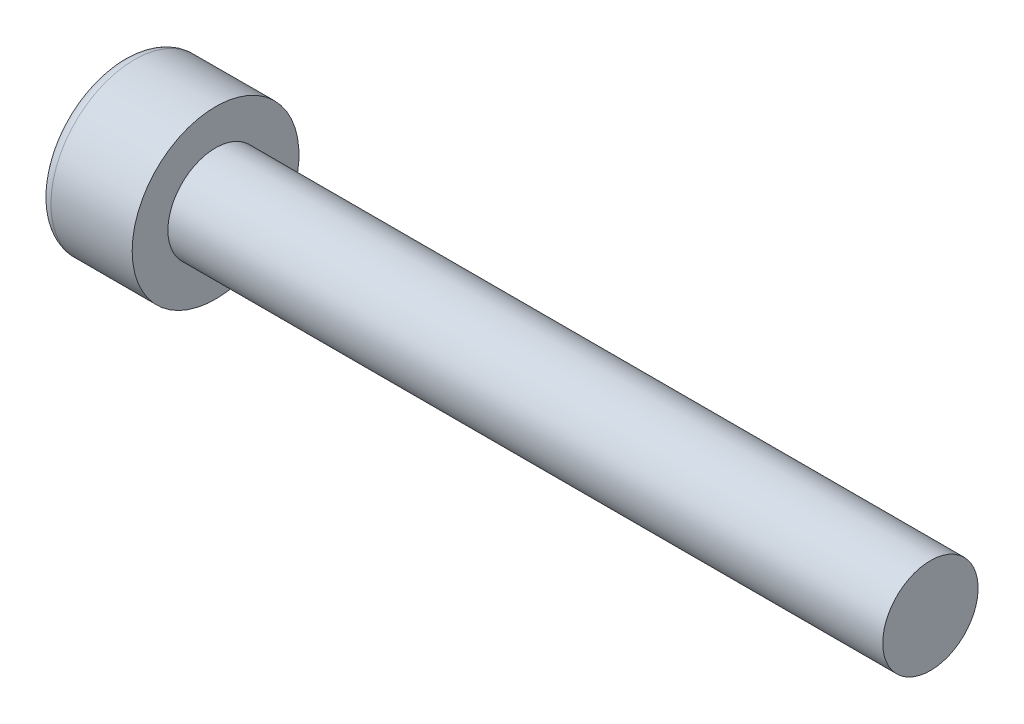
from build123d import *

# Parameters (mm, degrees)
CUT_EXTRUDE_1_DEPTH = 2
FILLET_1_R          = 0.5


with BuildPart() as part:
    # 草图1 → 旋转1 (revolve)
    with BuildSketch(Plane.XY):
        Polygon((0, 0), (0, 3.5), (3.91, 3.5), (3.91, 2), (33.91, 2), (33.91, 0), align=None)
    revolve(axis=Axis((0, 0, 0), (1, 0, 0)))

    # 草图2 → 切除-拉伸1 (cut)
    with BuildSketch(Plane.ZY):
        Polygon((-1.732050808, 0), (-0.866025404, -1.5), (0.866025404, -1.5), (1.732050808, 0), (0.866025404, 1.5), (-0.866025404, 1.5), align=None)
    extrude(amount=-CUT_EXTRUDE_1_DEPTH, mode=Mode.SUBTRACT)

    # 圆角1
    fillet_1_edges = [part.edges().sort_by_distance(p)[0] for p in [
        (0, -3.5, 0),
    ]]
    fillet(fillet_1_edges, radius=FILLET_1_R)


solid = part.part
